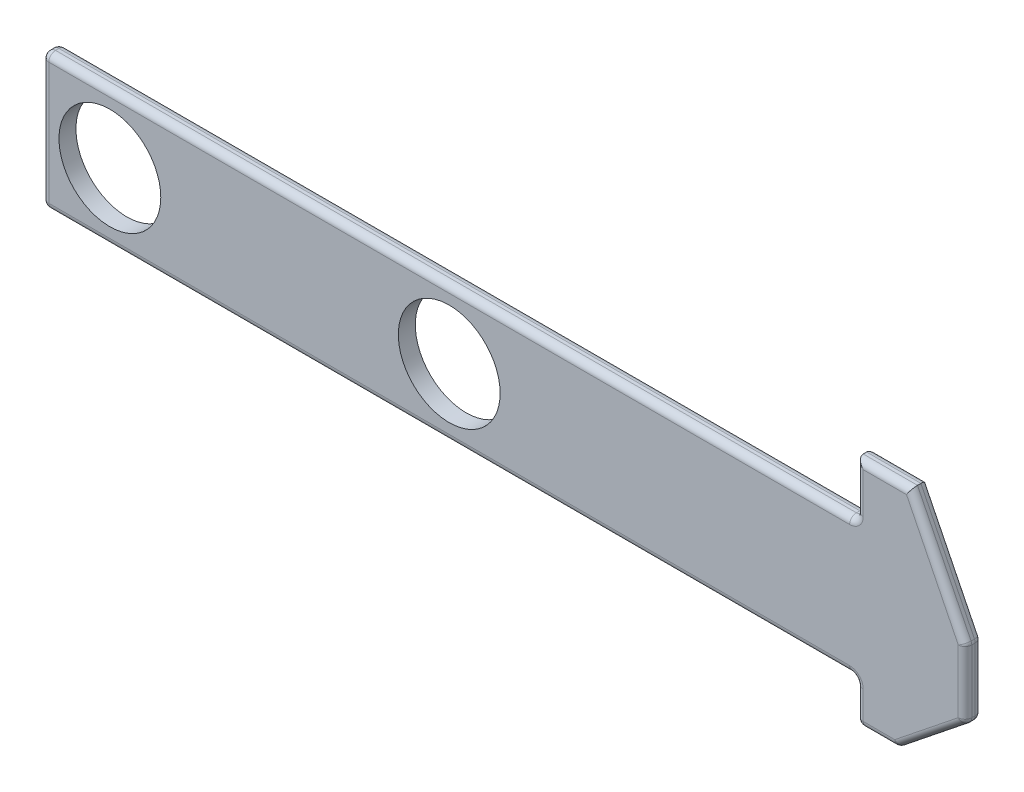
from build123d import *

# Parameters (mm, degrees)
BOSS_EXTRUDE1_DEPTH = 3.175
SKETCH2_R           = 9.525
CUT_EXTRUDE1_DEPTH  = 4.175
FILLET1_R           = 1.27


with BuildPart() as part:
    # Sketch1 → Boss-Extrude1 (new body)
    with BuildSketch(Plane.XY):
        Polygon((-76.2, 12.7), (76.2, 12.7), (76.2, 22.86), (86.36, 22.86), (96.52, 2.381865319), (96.52, -10.318134681), (83.82, -20.478134681), (76.2, -20.478134681), (76.2, -12.7), (-76.2, -12.7), align=None)
    extrude(amount=BOSS_EXTRUDE1_DEPTH)

    # Sketch2 → Cut-Extrude1 (cut, through all)
    with BuildSketch(Plane.XY.offset(3.175)):
        with Locations((-63.5, 0)):
            Circle(SKETCH2_R)
        Circle(SKETCH2_R)
    extrude(amount=-CUT_EXTRUDE1_DEPTH, mode=Mode.SUBTRACT)

    # Fillet1
    fillet1_edges = [part.edges().sort_by_distance(p)[0] for p in [
        (96.52, -3.968134681, 0),
        (90.17, -15.398134681, 0),
        (80.01, -20.478134681, 0),
        (76.2, -16.58906734, 0),
        (0, -12.7, 0),
        (-76.2, 0, 0),
        (0, 12.7, 0),
        (76.2, 17.78, 3.175),
        (76.2, 17.78, 0),
        (81.28, 22.86, 0),
        (91.44, 12.62093266, 0),
        (0, 12.7, 3.175),
        (96.52, 2.381865319, 1.5875),
        (96.52, -10.318134681, 1.5875),
        (83.82, -20.478134681, 1.5875),
        (76.2, -20.478134681, 1.5875),
        (76.2, -12.7, 1.5875),
        (-76.2, -12.7, 1.5875),
        (-76.2, 12.7, 1.5875),
        (76.2, 12.7, 1.5875),
        (-76.2, 0, 3.175),
        (0, -12.7, 3.175),
        (76.2, -16.58906734, 3.175),
        (80.01, -20.478134681, 3.175),
        (90.17, -15.398134681, 3.175),
        (96.52, -3.968134681, 3.175),
        (91.44, 12.62093266, 3.175),
        (81.28, 22.86, 3.175),
    ]]
    fillet(fillet1_edges, radius=FILLET1_R)


solid = part.part
